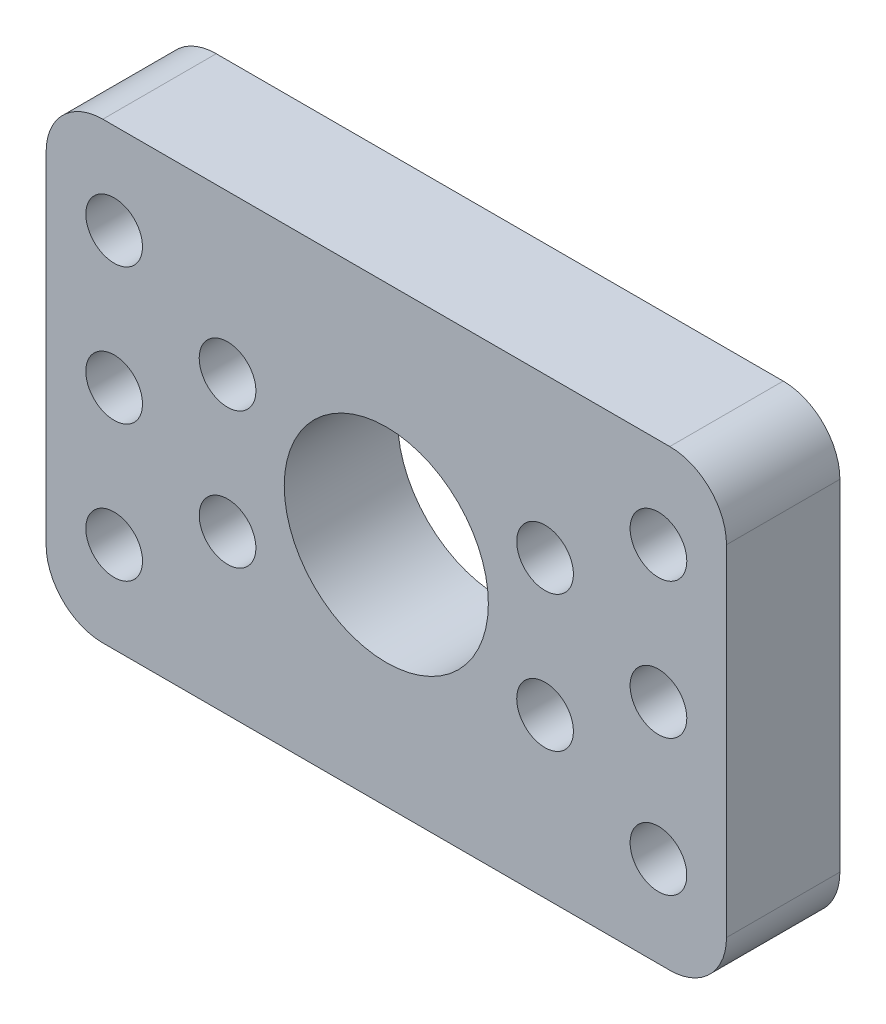
from build123d import *

# Parameters (mm, degrees)
SKETCH_1_R          = 9
EXTRUDE_1_DEPTH     = 10
SKETCH_3_R          = 2.5
CUT_EXTRUDE_1_DEPTH = 11


with BuildPart() as part:
    # ｽｹｯﾁ1 → ﾎﾞｽ - 押し出し1 (new body)
    with BuildSketch(Plane.XY):
        with BuildLine():
            Line((-25, 20), (25, 20))
            ThreePointArc((25, 20), (28.535533906, 18.535533906), (30, 15))
            Line((30, 15), (30, -15))
            ThreePointArc((30, -15), (28.535533906, -18.535533906), (25, -20))
            Line((25, -20), (-25, -20))
            ThreePointArc((-25, -20), (-28.535533906, -18.535533906), (-30, -15))
            Line((-30, -15), (-30, 15))
            ThreePointArc((-30, 15), (-28.535533906, 18.535533906), (-25, 20))
        make_face()
        Circle(SKETCH_1_R, mode=Mode.SUBTRACT)
    extrude(amount=EXTRUDE_1_DEPTH)

    # ｽｹｯﾁ3 → ｶｯﾄ - 押し出し1 (cut, through all)
    with BuildSketch(Plane.XY.offset(10)):
        with Locations((14, 6)):
            Circle(SKETCH_3_R)
        with Locations((24, 0)):
            Circle(SKETCH_3_R)
        with Locations((24, 12)):
            Circle(SKETCH_3_R)
        with Locations((24, -12)):
            Circle(SKETCH_3_R)
        with Locations((14, -6)):
            Circle(SKETCH_3_R)
    cut_extrude_1 = extrude(amount=-CUT_EXTRUDE_1_DEPTH, mode=Mode.SUBTRACT)

    # ﾐﾗｰ1: ｶｯﾄ - 押し出し1 across plane
    add(cut_extrude_1.mirror(Plane(origin=(0, 0, 0), x_dir=(0, 0, 1), z_dir=(1, 0, 0))), mode=Mode.SUBTRACT)


solid = part.part
